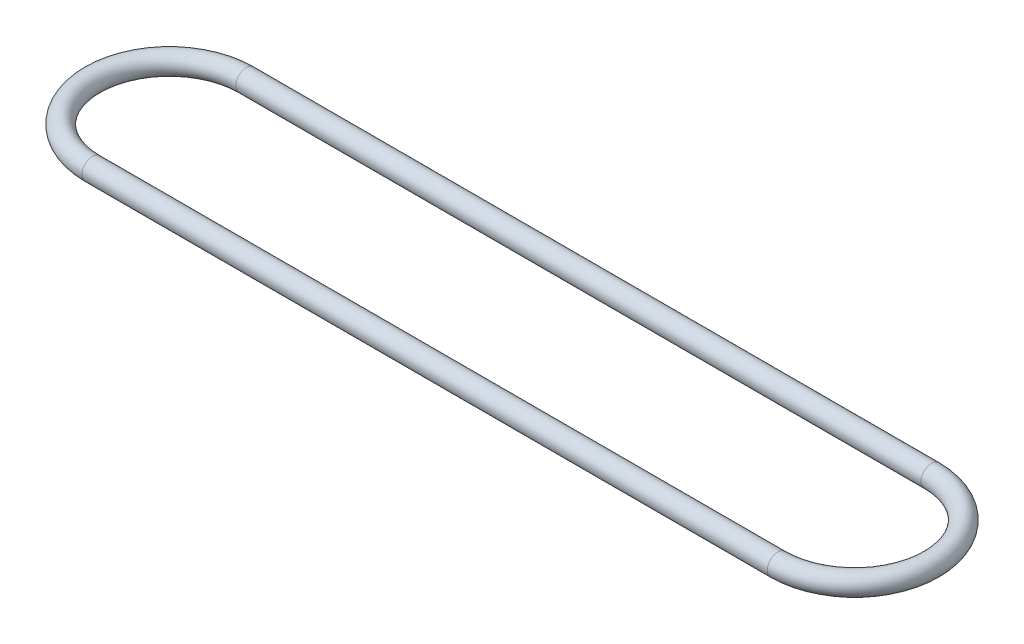
from build123d import *

# Parameters (mm, degrees)
CROQUIS5_R = 3.5


with BuildPart() as part:
    # Barrer1: sweep along a path in Croquis1
    with BuildLine(Plane(origin=(0, 0, 0), x_dir=(1, 0, 0), z_dir=(0, 1, 0))) as barrer1_path:
        Line((0, 25.58), (228, 25.58))
        ThreePointArc((228, 25.58), (253.58, 0), (228, -25.58))
        Line((228, -25.58), (0, -25.58))
        ThreePointArc((0, -25.58), (-25.58, 0), (0, 25.58))
    # Croquis5 → Barrer1 (sweep)
    with BuildSketch(Plane(origin=(0, 0, 0), x_dir=(0, 0, -1), z_dir=(1, 0, 0))):
        with Locations((25.58, 0)):
            Circle(CROQUIS5_R)
    sweep(path=barrer1_path.line)


solid = part.part
